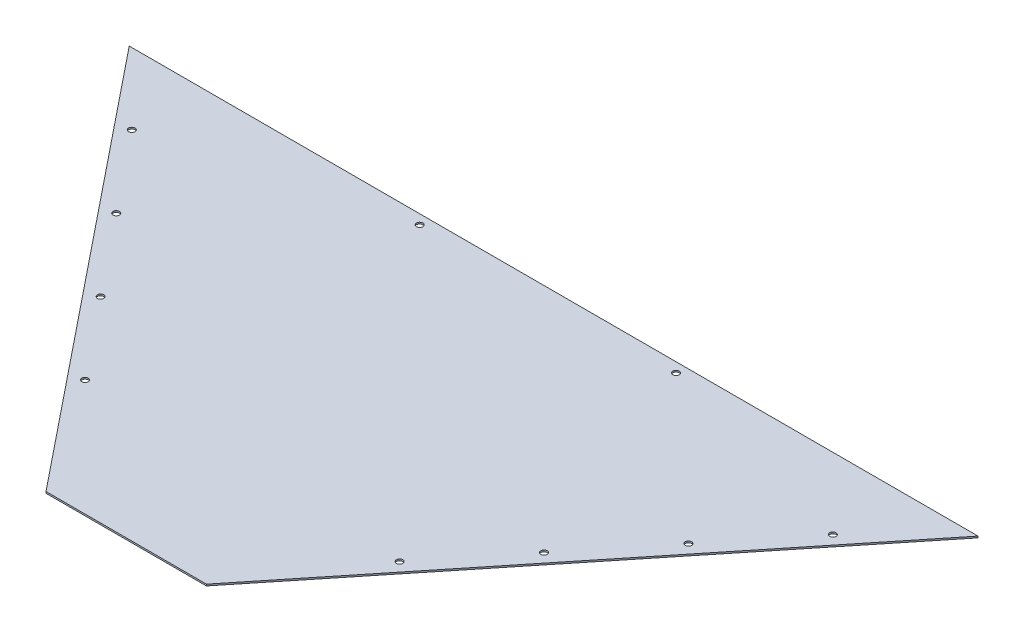
from build123d import *

# Parameters (mm, degrees)
BOSS_EXTRUDE1_DEPTH = 3.175
CUT_EXTRUDE1_REACH  = 5.175
SKETCH2_R           = 6.35
SKETCH4_R           = 6.35
CUT_EXTRUDE2_DEPTH  = 4.175


with BuildPart() as part:
    # Sketch1 → Boss-Extrude1 (new body)
    with BuildSketch(Plane(origin=(0, 0, 0), x_dir=(1, 0, 0), z_dir=(0, 1, 0))):
        Polygon((0, 0), (317.5, 0), (998.5375, 845.729357474), (-681.0375, 845.729357474), align=None)
    extrude(amount=BOSS_EXTRUDE1_DEPTH)

    # Sketch2 → Cut-Extrude1 (cut, up to next)
    with BuildSketch(Plane(origin=(0, 3.175, 0), x_dir=(-1, 0, 0), z_dir=(0, 1, 0)), mode=Mode.PRIVATE) as cut_extrude1_sk1:
        with Locations((87.1855, -826.679357474)):
            Circle(SKETCH2_R)
    cut_extrude1_tool1 = extrude(cut_extrude1_sk1.sketch, amount=-CUT_EXTRUDE1_REACH, mode=Mode.PRIVATE) & part.part
    add(cut_extrude1_tool1.solids().sort_by_distance((-87.1855, 3.175, -826.679357))[0], mode=Mode.SUBTRACT)
    # Sketch2 → Cut-Extrude1 (cut, up to next)
    with BuildSketch(Plane(origin=(0, 3.175, 0), x_dir=(-1, 0, 0), z_dir=(0, 1, 0)), mode=Mode.PRIVATE) as cut_extrude1_sk2:
        with Locations((-420.1795, -826.679357474)):
            Circle(SKETCH2_R)
    cut_extrude1_tool2 = extrude(cut_extrude1_sk2.sketch, amount=-CUT_EXTRUDE1_REACH, mode=Mode.PRIVATE) & part.part
    add(cut_extrude1_tool2.solids().sort_by_distance((420.1795, 3.175, -826.679357))[0], mode=Mode.SUBTRACT)

    # Sketch4 → Cut-Extrude2 (cut, through all)
    with BuildSketch(Plane(origin=(0, 3.175, 0), x_dir=(1, 0, 0), z_dir=(0, 1, 0))):
        with Locations((852.308331977, 704.636230713)):
            Circle(SKETCH4_R)
        with Locations((469.971489871, 229.840801956)):
            Circle(SKETCH4_R)
        with Locations((724.862717941, 546.371087794)):
            Circle(SKETCH4_R)
        with Locations((597.417103906, 388.105944875)):
            Circle(SKETCH4_R)
        with Locations((-534.808331977, 704.636230713)):
            Circle(SKETCH4_R)
        with Locations((-407.362717941, 546.371087794)):
            Circle(SKETCH4_R)
        with Locations((-279.917103906, 388.105944875)):
            Circle(SKETCH4_R)
        with Locations((-152.471489871, 229.840801956)):
            Circle(SKETCH4_R)
    extrude(amount=-CUT_EXTRUDE2_DEPTH, mode=Mode.SUBTRACT)


solid = part.part
